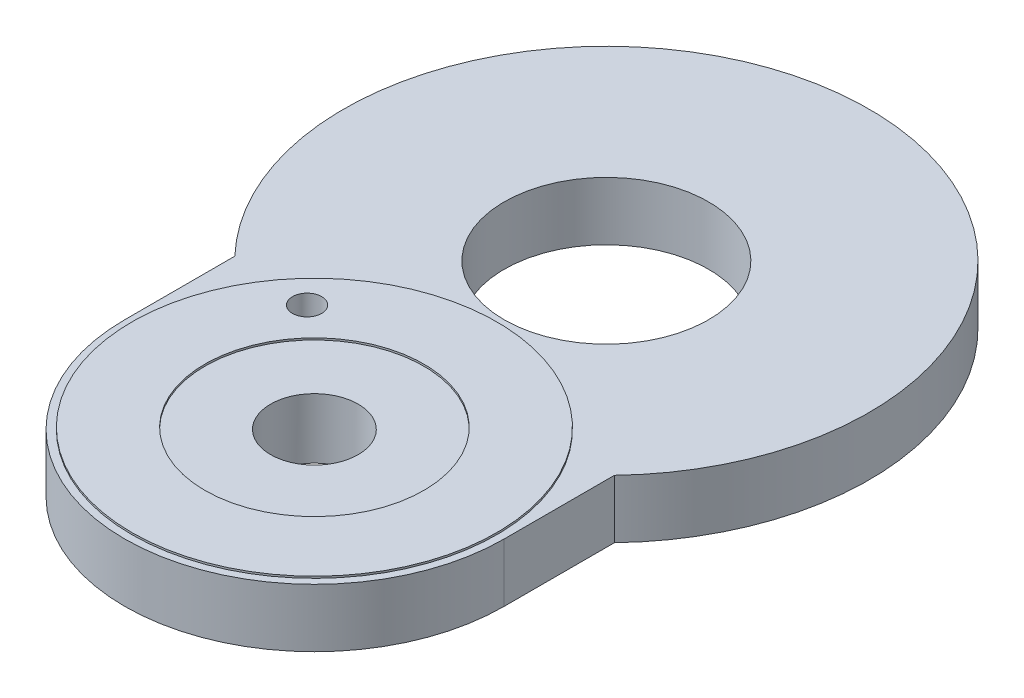
from build123d import *

# Parameters (mm, degrees)
SKETCH1_R           = 1.4
BOSS_EXTRUDE1_DEPTH = 0.8
SKETCH2_R           = 0.6
SKETCH2_R_2         = 0.2
CUT_EXTRUDE1_DEPTH  = 0.8
SKETCH3_R           = 2.5
SKETCH3_R_2         = 1.5
SKETCH3_R_3         = 0.2
BOSS_EXTRUDE2_DEPTH = 0.0254
SKETCH4_R           = 0.6
SKETCH4_R_2         = 0.2
BOSS_EXTRUDE3_DEPTH = 0.0254


with BuildPart() as part:
    # Sketch1 → Boss-Extrude1 (new body)
    with BuildSketch(Plane(origin=(0, 0, 0), x_dir=(1, 0, 0), z_dir=(0, 1, 0))):
        with BuildLine():
            Line((-2.6, 0), (-2.6, 1.51002008))
            ThreePointArc((-2.6, 1.51002008), (0, 7.6), (2.6, 1.51002008))
            Line((2.6, 1.51002008), (2.6, 0))
            ThreePointArc((2.6, 0), (0, -2.6), (-2.6, 0))
        make_face()
        with Locations(Location((0, 4, 0), (0, 0, 270))):
            Circle(SKETCH1_R, mode=Mode.SUBTRACT)
    extrude(amount=BOSS_EXTRUDE1_DEPTH)

    # Sketch2 → Cut-Extrude1 (cut)
    with BuildSketch(Plane(origin=(0, 0.8, 0), x_dir=(1, 0, 0), z_dir=(0, 1, 0))):
        with Locations(Location((0, 0, 0), (0, 0, 270))):
            Circle(SKETCH2_R)
        with Locations(Location((-1.5, 1.4, 0), (0, 0, 270))):
            Circle(SKETCH2_R_2)
    extrude(amount=-CUT_EXTRUDE1_DEPTH, mode=Mode.SUBTRACT)

    # Sketch3 → Boss-Extrude2 (add)
    with BuildSketch(Plane(origin=(0, 0.8, 0), x_dir=(1, 0, 0), z_dir=(0, 1, 0))):
        with Locations(Location((0, 0, 0), (0, 0, 270))):
            Circle(SKETCH3_R)
        with Locations(Location((0, 0, 0), (0, 0, 270))):
            Circle(SKETCH3_R_2, mode=Mode.SUBTRACT)
        with Locations(Location((-1.5, 1.4, 0), (0, 0, 270))):
            Circle(SKETCH3_R_3, mode=Mode.SUBTRACT)
    extrude(amount=BOSS_EXTRUDE2_DEPTH)

    # Sketch4 → Boss-Extrude3 (add)
    with BuildSketch(Plane.XZ):
        with BuildLine():
            ThreePointArc((-1.270694255, -1.797463292), (-1.103147311, -1.172970136), (-1.727640466, -1.005423192))
            ThreePointArc((-1.727640466, -1.005423192), (0.511420208, -7.419163817), (0.775806401, -0.63097102))
            ThreePointArc((0.775806401, -0.63097102), (-0.211741678, 0.977325668), (-0.445093544, -0.89548408))
            ThreePointArc((-0.445093544, -0.89548408), (-0.358340982, -1.283942918), (0, -1.4572))
            ThreePointArc((0, -1.4572), (0.657731518, -6.456261609), (-1.270694255, -1.797463292))
        make_face()
        with Locations(Location((0, 0, 0), (0, 0, 90))):
            Circle(SKETCH4_R, mode=Mode.SUBTRACT)
        with Locations(Location((-1.5, -1.4, 0), (0, 0, 90))):
            Circle(SKETCH4_R_2, mode=Mode.SUBTRACT)
    extrude(amount=BOSS_EXTRUDE3_DEPTH)


solid = part.part
